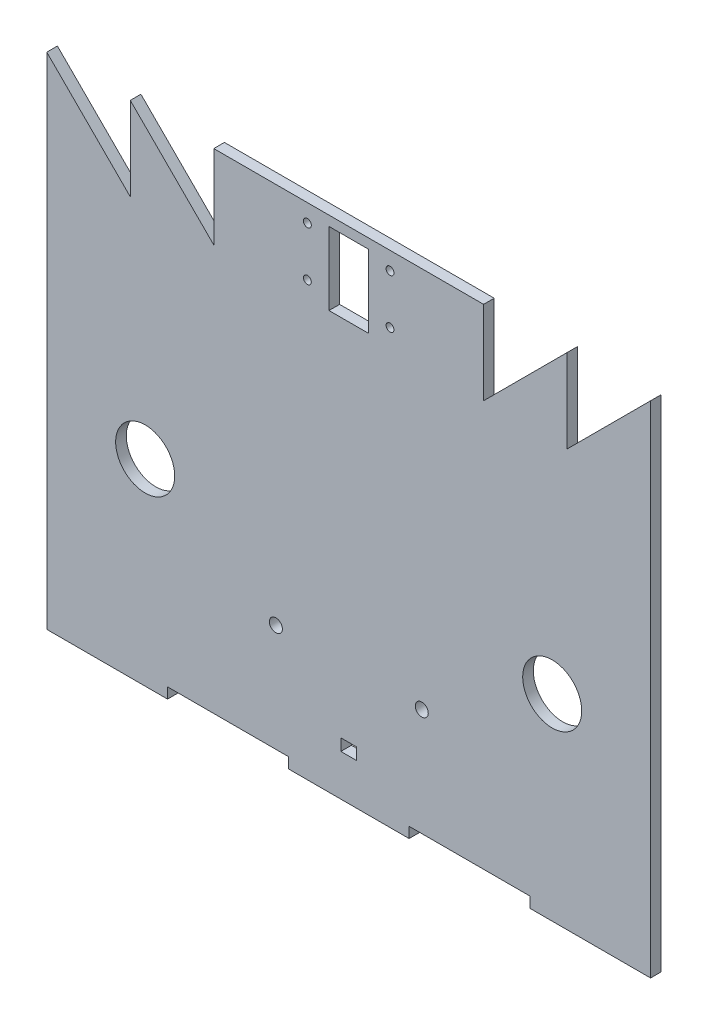
from build123d import *

# Parameters (mm, degrees)
SKETCH1_R           = 1.65
SKETCH1_R_2         = 7.5
SKETCH1_R_3         = 1
SKETCH1_W           = 4
SKETCH1_H           = 3
SKETCH1_W_2         = 10
SKETCH1_H_2         = 18.5
BOSS_EXTRUDE3_DEPTH = 2.7


with BuildPart() as part:
    # Sketch1 → Boss-Extrude3 (new body)
    with BuildSketch(Plane.XY):
        Polygon((-46.02, -28), (-46.02, -25.3), (-15.34, -25.3), (-15.34, -28), (15.34, -28), (15.34, -25.3), (46.02, -25.3), (46.02, -28), (76.7, -28), (76.7, 99), (55.486796564, 77.786796564), (55.486796564, 99), (34.273593129, 77.786796564), (34.273593129, 99), (-34.273593129, 99), (-34.273593129, 77.786796564), (-55.486796564, 99), (-55.486796564, 77.786796564), (-76.7, 99), (-76.7, -28), align=None)
        with Locations((-18.5, 2)):
            Circle(SKETCH1_R, mode=Mode.SUBTRACT)
        with Locations((18.567940233, 2)):
            Circle(SKETCH1_R, mode=Mode.SUBTRACT)
        with Locations((-51.7, 22)):
            Circle(SKETCH1_R_2, mode=Mode.SUBTRACT)
        with Locations((51.7, 22)):
            Circle(SKETCH1_R_2, mode=Mode.SUBTRACT)
        with Locations((10.5, 94.5)):
            Circle(SKETCH1_R_3, mode=Mode.SUBTRACT)
        with Locations((-10.5, 82)):
            Circle(SKETCH1_R_3, mode=Mode.SUBTRACT)
        with Locations((-10.5, 94.5)):
            Circle(SKETCH1_R_3, mode=Mode.SUBTRACT)
        with Locations((10.5, 82)):
            Circle(SKETCH1_R_3, mode=Mode.SUBTRACT)
        with Locations((0, -16)):
            Rectangle(SKETCH1_W, SKETCH1_H, mode=Mode.SUBTRACT)
        with Locations((0, 87.25)):
            Rectangle(SKETCH1_W_2, SKETCH1_H_2, mode=Mode.SUBTRACT)
    extrude(amount=BOSS_EXTRUDE3_DEPTH)


solid = part.part
